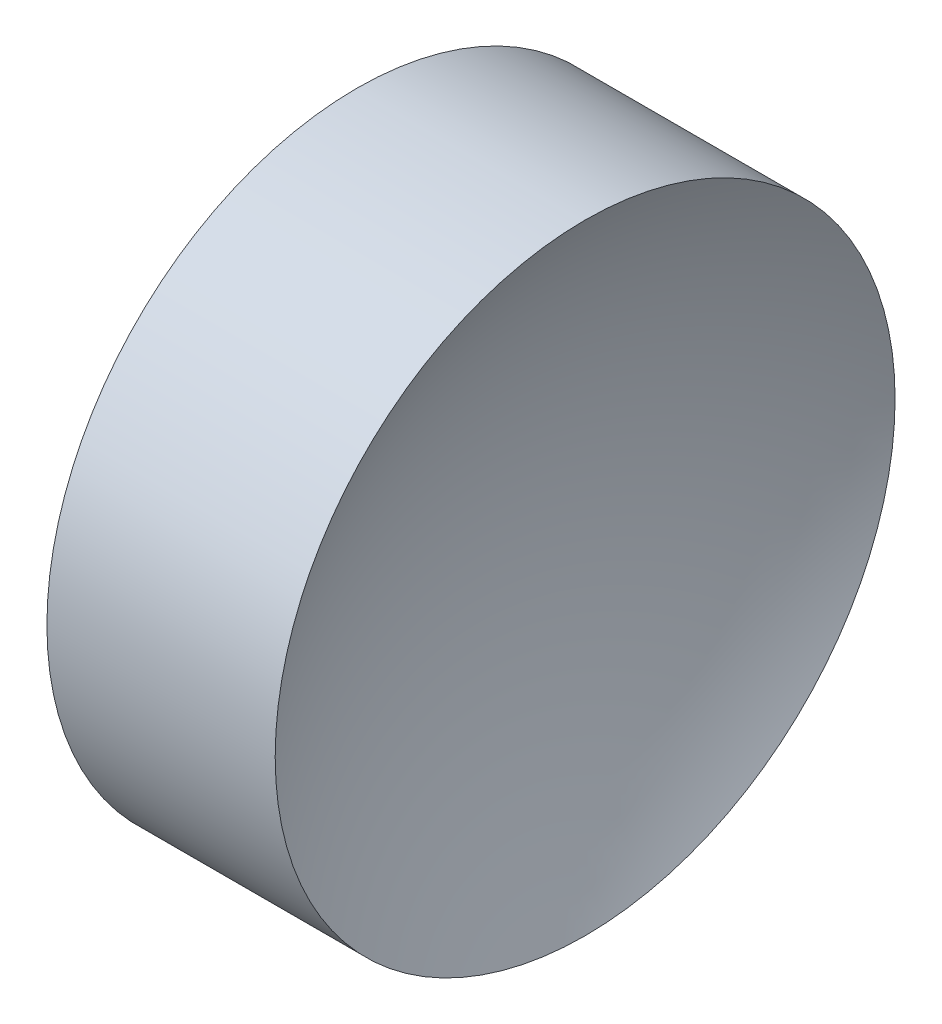
from build123d import *


with BuildPart() as part:
    # 草图1 → 旋转1 (revolve)
    with BuildSketch(Plane.XY, mode=Mode.PRIVATE) as revolve_1_sk:
        with BuildLine():
            Line((22.172189475, 13.044520575), (22.172189475, 16.194520575))
            Line((22.172189475, 16.194520575), (24.492189475, 16.194520575))
            ThreePointArc((24.492189475, 16.194520575), (23.880399724, 14.672036546), (23.671986482, 13.044520575))
            Line((23.671986482, 13.044520575), (22.172189475, 13.044520575))
        make_face()
    revolve(revolve_1_sk.sketch.rotate(Axis((21.224930557, 13.044520575, 0), (1, 0, 0)), 180), axis=Axis((21.224930557, 13.044520575, 0), (1, 0, 0)))  # turned: the seam where the file's is


solid = part.part
